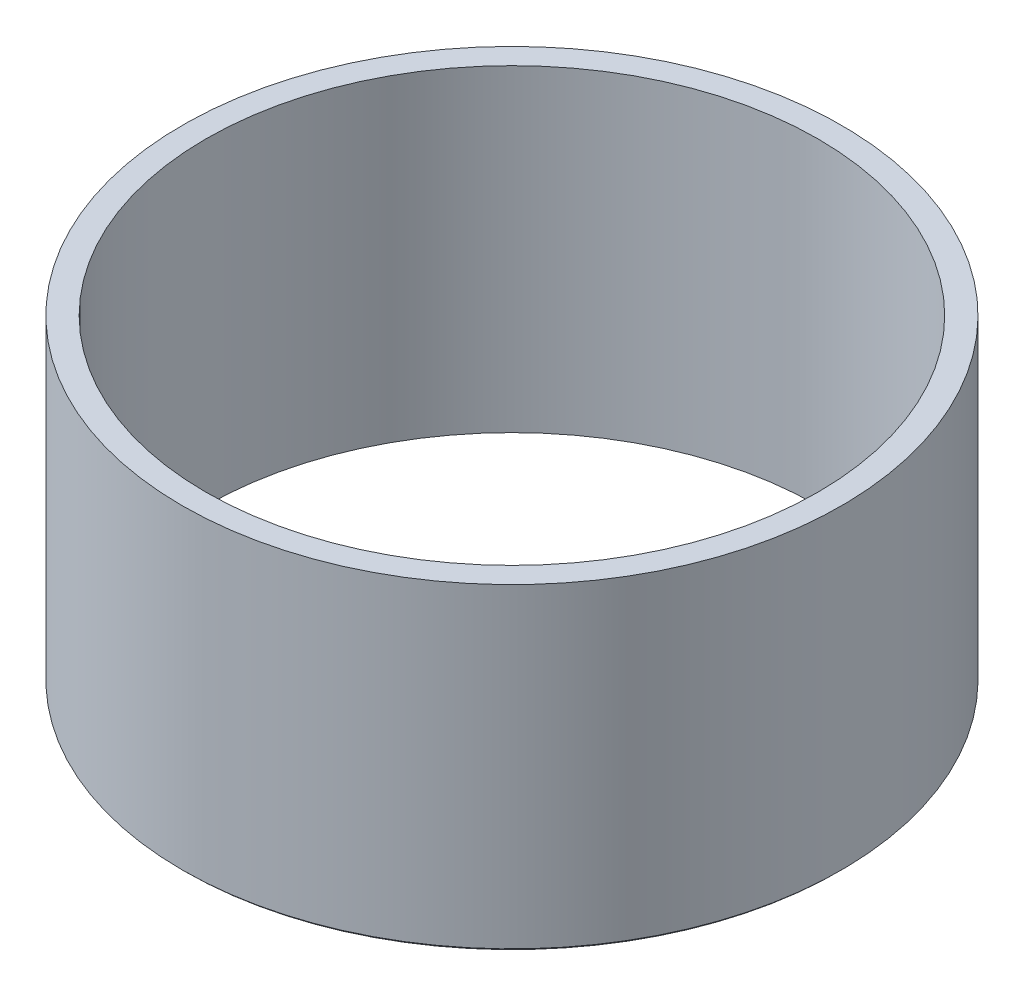
from build123d import *

# Parameters (mm, degrees)
CROQUIS1_R              = 14
CROQUIS1_R_2            = 13
SALIENTE_EXTRUIR1_DEPTH = 13.5
CHAFL_N1_SIZE           = 0.1


with BuildPart() as part:
    # Croquis1 → Saliente-Extruir1 (new body)
    with BuildSketch(Plane(origin=(0, 0, 0), x_dir=(1, 0, 0), z_dir=(0, 1, 0))):
        Circle(CROQUIS1_R)
        Circle(CROQUIS1_R_2, mode=Mode.SUBTRACT)
    extrude(amount=SALIENTE_EXTRUIR1_DEPTH)

    # Chaflán1
    chafl_n1_edges = [part.edges().sort_by_distance(p)[0] for p in [
        (-14, 0, 0),
    ]]
    chamfer(chafl_n1_edges, length=CHAFL_N1_SIZE)


solid = part.part
